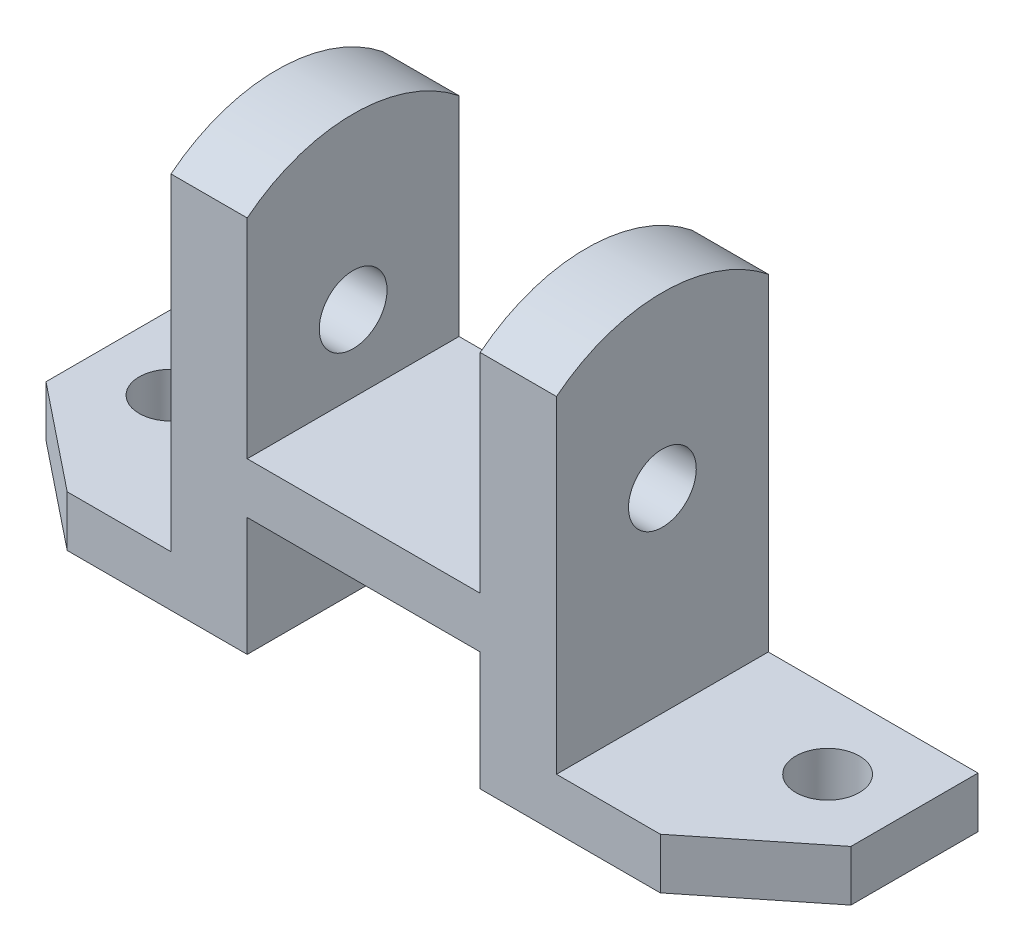
from build123d import *

# Parameters (mm, degrees)
SKETCH1_R           = 7.5
BOSS_EXTRUDE1_DEPTH = 98
SKETCH2_W           = 49.5
SKETCH2_H           = 86
SKETCH2_W_2         = 55
SKETCH2_H_2         = 58
CUT_EXTRUDE1_DEPTH  = 51
SKETCH3_W           = 55
SKETCH3_H           = 28
CUT_EXTRUDE2_DEPTH  = 51
SKETCH4_W           = 55
SKETCH4_H           = 8
BOSS_EXTRUDE2_DEPTH = 28
SKETCH5_R           = 8
CUT_EXTRUDE3_DEPTH  = 141.5


with BuildPart() as part:
    # Sketch1 → Boss-Extrude1 (new body)
    with BuildSketch(Plane(origin=(0, 0, 0), x_dir=(1, 0, 0), z_dir=(0, 1, 0))):
        Polygon((-95, 25), (-95, -5), (-70, -25), (70, -25), (95, -5), (95, 25), align=None)
        with Locations((-77.5, 7)):
            Circle(SKETCH1_R, mode=Mode.SUBTRACT)
        with Locations((77.5, 7)):
            Circle(SKETCH1_R, mode=Mode.SUBTRACT)
    extrude(amount=BOSS_EXTRUDE1_DEPTH)

    # Sketch2 → Cut-Extrude1 (cut, through all)
    with BuildSketch(Plane.XY.offset(25)):
        with Locations((-70.25, 55)):
            Rectangle(SKETCH2_W, SKETCH2_H)
        with Locations((70.25, 55)):
            Rectangle(SKETCH2_W, SKETCH2_H)
        with Locations((0, 69)):
            Rectangle(SKETCH2_W_2, SKETCH2_H_2)
    extrude(amount=-CUT_EXTRUDE1_DEPTH, mode=Mode.SUBTRACT)

    # Sketch3 → Cut-Extrude2 (cut, through all)
    with BuildSketch(Plane.XY.offset(25)):
        with Locations((0, 14)):
            Rectangle(SKETCH3_W, SKETCH3_H)
    extrude(amount=-CUT_EXTRUDE2_DEPTH, mode=Mode.SUBTRACT)

    # Sketch4 → Boss-Extrude2 (add)
    with BuildSketch(Plane.XZ.offset(-28)):
        with Locations((0, -7)):
            Rectangle(SKETCH4_W, SKETCH4_H)
    extrude(amount=BOSS_EXTRUDE2_DEPTH)

    # Sketch5 → Cut-Extrude3 (cut, through all)
    with BuildSketch(Plane(origin=(45.5, 0, 0), x_dir=(0, 0, -1), z_dir=(1, 0, 0))):
        with BuildLine():
            ThreePointArc((2.26e-07, 98), (13.247648961, 95.742546244), (25, 89.224989992))
            Line((25, 89.224989992), (25, 98))
            Line((25, 98), (2.26e-07, 98))
        make_face()
        with BuildLine():
            ThreePointArc((-25, 89.224989992), (-13.247648747, 95.742546319), (2.26e-07, 98))
            Line((2.26e-07, 98), (-25, 98))
            Line((-25, 98), (-25, 89.224989992))
        make_face()
        with Locations((0, 58)):
            Circle(SKETCH5_R)
    extrude(amount=-CUT_EXTRUDE3_DEPTH, mode=Mode.SUBTRACT)


solid = part.part
